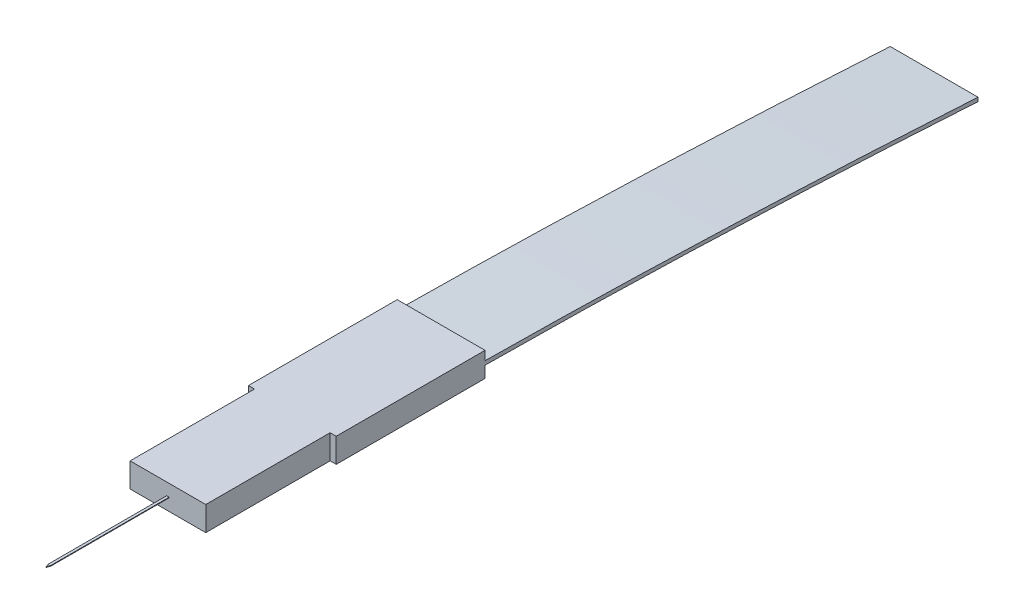
from build123d import *

# Parameters (mm, degrees)
SKETCH1_W           = 6.2
SKETCH1_H           = 10.2
BOSS_EXTRUDE1_DEPTH = 2
SKETCH3_W           = 0.2
SKETCH3_H           = 0.05
BOSS_EXTRUDE3_DEPTH = 10
CUT_EXTRUDE1_DEPTH  = 0.05
BOSS_EXTRUDE4_DEPTH = 7.2


with BuildPart() as part:
    # Sketch1 → Boss-Extrude1 (new body)
    with BuildSketch(Plane(origin=(0, 0, 0), x_dir=(1, 0, 0), z_dir=(0, 1, 0))):
        Polygon((-3.6, -6.1), (-3.1, -6.1), (3.1, -6.1), (3.6, -6.1), (3.6, 6.1), (-3.6, 6.1), align=None)
        with Locations((0, -11.2)):
            Rectangle(SKETCH1_W, SKETCH1_H)
    extrude(amount=BOSS_EXTRUDE1_DEPTH)

    # Sketch3 → Boss-Extrude3 (add)
    with BuildSketch(Plane.XY.offset(16.3)):
        with Locations((0, 1)):
            Rectangle(SKETCH3_W, SKETCH3_H)
    extrude(amount=BOSS_EXTRUDE3_DEPTH)

    # Sketch4 → Cut-Extrude1 (cut)
    with BuildSketch(Plane.XZ.offset(-0.975)):
        Polygon((0.1, 26.3), (0, 26.3), (0.1, 26), align=None)
        Polygon((-0.1, 26.3), (-0.1, 26), (0, 26.3), align=None)
    extrude(amount=-CUT_EXTRUDE1_DEPTH, mode=Mode.SUBTRACT)

    # Sketch5 → Boss-Extrude4 (add)
    with BuildSketch(Plane(origin=(3.6, 0, 0), x_dir=(0, 0, -1), z_dir=(1, 0, 0))):
        with BuildLine():
            Line((6.1, 1.261801628), (6.1, 0.942348221))
            add(Edge.make_bspline(
                [(6.1, 0.942348221), (24.518318323, 0.810344541), (46.52588684, -0.554134336)],
                knots=[0, 0, 0, 1, 1, 1], degree=2))
            Line((46.52588684, -0.554134336), (46.52588684, -0.234680929))
            add(Edge.make_bspline(
                [(6.1, 1.261801628), (24.562430755, 1.083380731), (46.52588684, -0.234680929)],
                knots=[0, 0, 0, 1, 1, 1], degree=2))
        make_face()
    extrude(amount=-BOSS_EXTRUDE4_DEPTH)


solid = part.part
